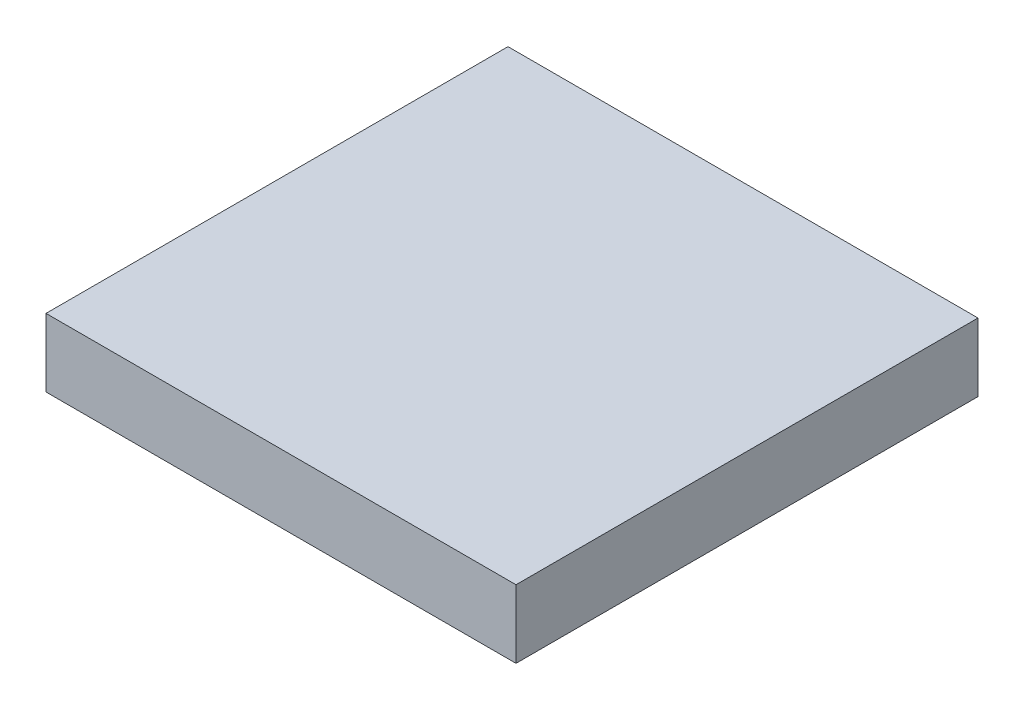
from build123d import *

# Parameters (mm, degrees)
SKETCH_1_W      = 176
SKETCH_1_H      = 173
EXTRUDE_1_DEPTH = 25.5


with BuildPart() as part:
    # 草圖1 → 填料-伸長1 (new body)
    with BuildSketch(Plane(origin=(0, 0, 0), x_dir=(1, 0, 0), z_dir=(0, 1, 0))):
        with Locations((14.215384615, -52.653846154)):
            Rectangle(SKETCH_1_W, SKETCH_1_H)
    extrude(amount=EXTRUDE_1_DEPTH)


solid = part.part
